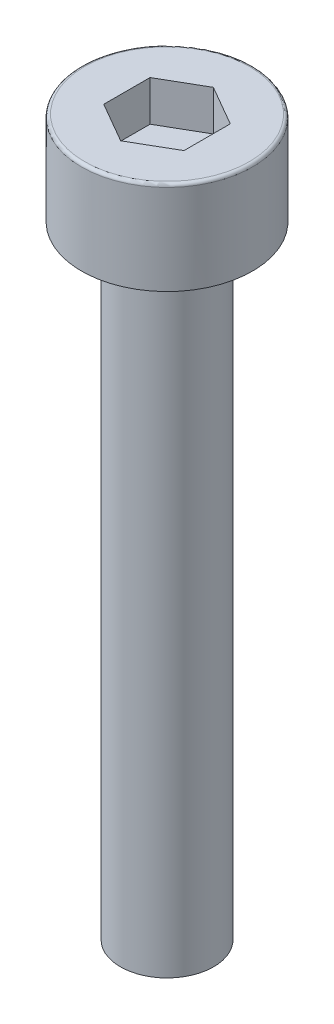
from build123d import *

# Parameters (mm, degrees)
CUT_EXTRUDE1_DEPTH = 1.3
FILLET1_R          = 0.1


with BuildPart() as part:
    # Sketch1 → Revolve1 (revolve)
    with BuildSketch(Plane.XY):
        Polygon((0, 0), (0, 23), (2.75, 23), (2.75, 20), (1.5, 20), (1.5, 0), align=None)
    revolve(axis=Axis((0, 0, 0), (0, 1, 0)))

    # Sketch2 → Cut-Extrude1 (cut)
    with BuildSketch(Plane(origin=(0, 23, 0), x_dir=(1, 0, 0), z_dir=(0, 1, 0))):
        Polygon((0, 1.489563695), (-1.29, 0.744781847), (-1.29, -0.744781847), (0, -1.489563695), (1.29, -0.744781847), (1.29, 0.744781847), align=None)
    extrude(amount=-CUT_EXTRUDE1_DEPTH, mode=Mode.SUBTRACT)

    # Fillet1
    fillet1_edges = [part.edges().sort_by_distance(p)[0] for p in [
        (-2.75, 23, 0),
    ]]
    fillet(fillet1_edges, radius=FILLET1_R)


solid = part.part
